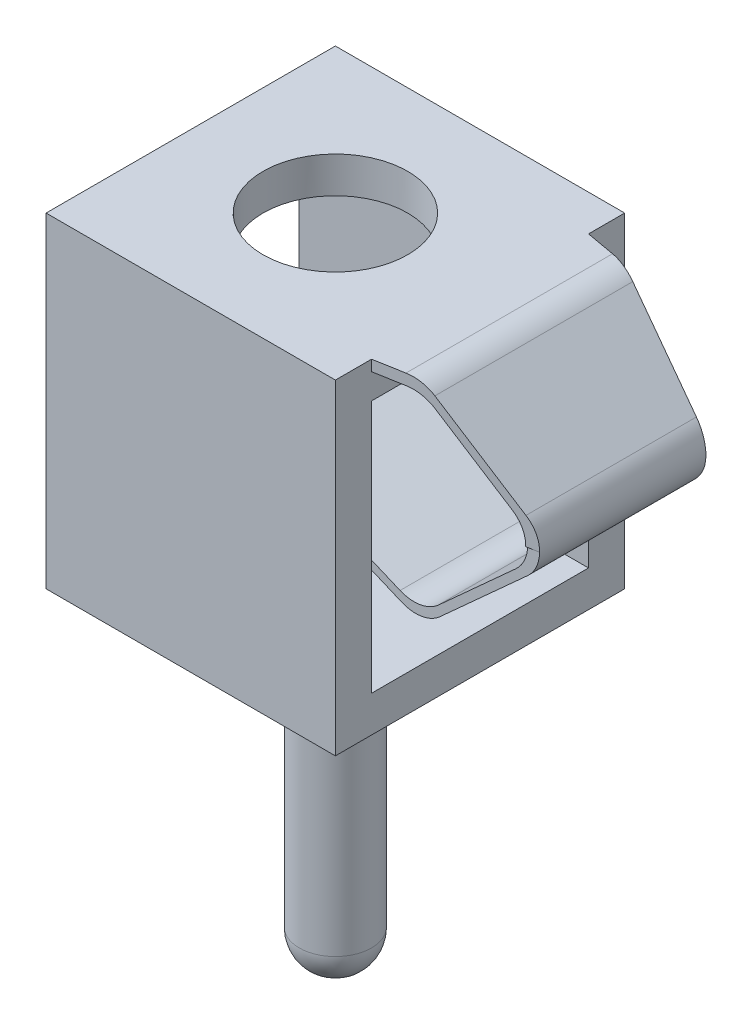
from build123d import *

# Parameters (mm, degrees)
SKETCH1_W               = 4
SKETCH1_H               = 4.5
SKETCH1_W_2             = 3
SKETCH1_H_2             = 3.5
BOSS_EXTRUDE1_DEPTH     = 4
SKETCH2_R               = 0.5
BOSS_EXTRUDE2_DEPTH     = 4.55
FILLET1_R               = 0.5
SKETCH3_R               = 1
CUT_EXTRUDE1_DEPTH      = 2.55
BOSS_EXTRUDE3_START     = -0.5
BOSS_EXTRUDE3_DEPTH     = 3
CUT_EXTRUDE2_DEPTH      = 1.5
SKETCH7_W               = 0.349986897
SKETCH7_H               = 2
CUT_EXTRUDE3_DEPTH      = 4.5
CUT_EXTRUDE3_DEPTH_BACK = 7.5


with BuildPart() as part:
    # Sketch1 → Boss-Extrude1 (new body)
    with BuildSketch(Plane(origin=(0, 0, 0), x_dir=(0, 0, -1), z_dir=(1, 0, 0))):
        Rectangle(SKETCH1_W, SKETCH1_H)
        Rectangle(SKETCH1_W_2, SKETCH1_H_2, mode=Mode.SUBTRACT)
    extrude(amount=BOSS_EXTRUDE1_DEPTH)

    # Sketch2 → Boss-Extrude2 (add)
    with BuildSketch(Plane.XZ.offset(2.25)):
        with Locations((2, 0)):
            Circle(SKETCH2_R)
    extrude(amount=BOSS_EXTRUDE2_DEPTH)

    # Fillet1
    fillet1_edges = [part.edges().sort_by_distance(p)[0] for p in [
        (1.5, -6.8, 0),
    ]]
    fillet(fillet1_edges, radius=FILLET1_R)

    # Sketch3 → Cut-Extrude1 (cut)
    with BuildSketch(Plane(origin=(0, 2.25, 0), x_dir=(1, 0, 0), z_dir=(0, 1, 0))):
        with Locations((2, 0)):
            Circle(SKETCH3_R)
    extrude(amount=-CUT_EXTRUDE1_DEPTH, mode=Mode.SUBTRACT)

    # Sketch5 → Boss-Extrude3 (add)
    with BuildSketch(Plane.XY.offset(2).offset(BOSS_EXTRUDE3_START)):
        with BuildLine():
            Line((4, 2.25), (4.403883865, 2.25))
            ThreePointArc((4.403883865, 2.25), (4.586458051, 2.215474668), (4.743818499, 2.116666667))
            Line((4.743818499, 2.116666667), (5.813186883, 1.125261165))
            ThreePointArc((5.813186883, 1.125261165), (5.973243782, 0.755684806), (5.808896382, 0.387996313))
            Line((5.808896382, 0.387996313), (4.596439486, -0.710104164))
            ThreePointArc((4.596439486, -0.710104164), (4.344752484, -0.832406779), (4.066768671, -0.800324431))
            Line((4.066768671, -0.800324431), (1.595431684, 0.240227029))
            Line((1.595431684, 0.240227029), (1.595431684, 0.359579889))
            Line((1.595431684, 0.359579889), (4.04486832, -0.671750473))
            ThreePointArc((4.04486832, -0.671750473), (4.322852132, -0.703832821), (4.574539135, -0.581530206))
            Line((4.574539135, -0.581530206), (5.646078544, 0.388943829))
            ThreePointArc((5.646078544, 0.388943829), (5.810425944, 0.756632322), (5.650369044, 1.126208681))
            Line((5.650369044, 1.126208681), (4.743818499, 1.966666667))
            ThreePointArc((4.743818499, 1.966666667), (4.586458051, 2.065474668), (4.403883865, 2.1))
            Line((4.403883865, 2.1), (4, 2.1))
            Line((4, 2.1), (4, 2.25))
        make_face()
    extrude(amount=-BOSS_EXTRUDE3_DEPTH)

    # Sketch6 → Cut-Extrude2 (cut)
    with BuildSketch(Plane(origin=(0, 2.25, 0), x_dir=(1, 0, 0), z_dir=(0, 1, 0))):
        Polygon((4, 1.5), (5.973252249, 1.15), (5.973252249, 1.5), align=None)
        Polygon((4, -1.5), (5.973252249, -1.15), (5.973252249, -1.5), align=None)
    extrude(amount=-CUT_EXTRUDE2_DEPTH, mode=Mode.SUBTRACT)

    # Sketch7 → Cut-Extrude3 (cut, two sides)
    with BuildSketch(Plane(origin=(4, 0, 0), x_dir=(0, 0, -1), z_dir=(1, 0, 0))) as cut_extrude3_sk:
        with Locations((-1.325006552, -0.25)):
            Rectangle(SKETCH7_W, SKETCH7_H)
        with Locations((1.325006552, -0.25)):
            Rectangle(SKETCH7_W, SKETCH7_H)
    extrude(amount=CUT_EXTRUDE3_DEPTH, mode=Mode.SUBTRACT)
    extrude(cut_extrude3_sk.sketch, amount=-CUT_EXTRUDE3_DEPTH_BACK, mode=Mode.SUBTRACT)


solid = part.part
